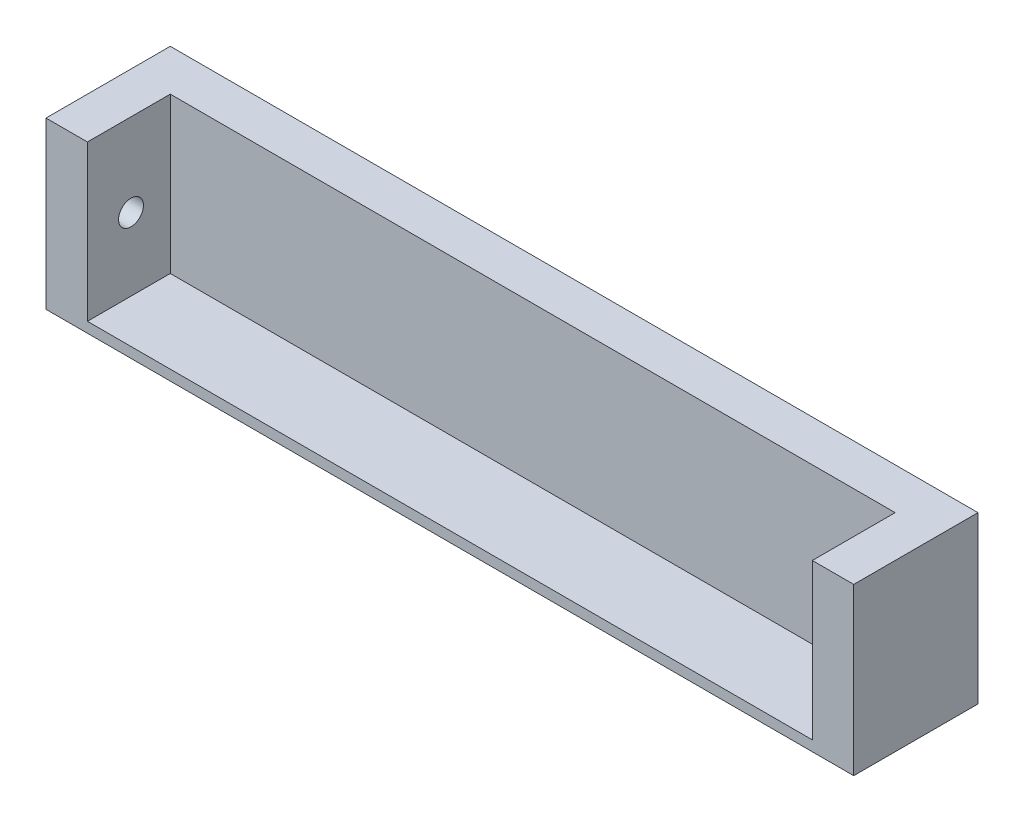
from build123d import *

# Parameters (mm, degrees)
SKETCH2_W               = 390
SKETCH2_H               = 80
BOSS_EXTRUDE1_DEPTH     = 60
SKETCH4_W               = 350
SKETCH4_H               = 75
CUT_EXTRUDE1_DEPTH      = 40
SKETCH5_R               = 6
CUT_EXTRUDE2_DEPTH      = 360
CUT_EXTRUDE2_DEPTH_BACK = 10


with BuildPart() as part:
    # Sketch2 → Boss-Extrude1 (new body)
    with BuildSketch(Plane.XY):
        with Locations((195, 40)):
            Rectangle(SKETCH2_W, SKETCH2_H)
    extrude(amount=BOSS_EXTRUDE1_DEPTH)

    # Sketch4 → Cut-Extrude1 (cut)
    with BuildSketch(Plane.XY.offset(60)):
        with Locations((195, 42.5)):
            Rectangle(SKETCH4_W, SKETCH4_H)
    extrude(amount=-CUT_EXTRUDE1_DEPTH, mode=Mode.SUBTRACT)

    # Sketch5 → Cut-Extrude2 (cut, two sides)
    with BuildSketch(Plane(origin=(20, 0, 0), x_dir=(0, 0, -1), z_dir=(1, 0, 0))) as cut_extrude2_sk:
        with Locations((-38.957689145, 40)):
            Circle(SKETCH5_R)
    extrude(amount=CUT_EXTRUDE2_DEPTH, mode=Mode.SUBTRACT)
    extrude(cut_extrude2_sk.sketch, amount=-CUT_EXTRUDE2_DEPTH_BACK, mode=Mode.SUBTRACT)


solid = part.part
